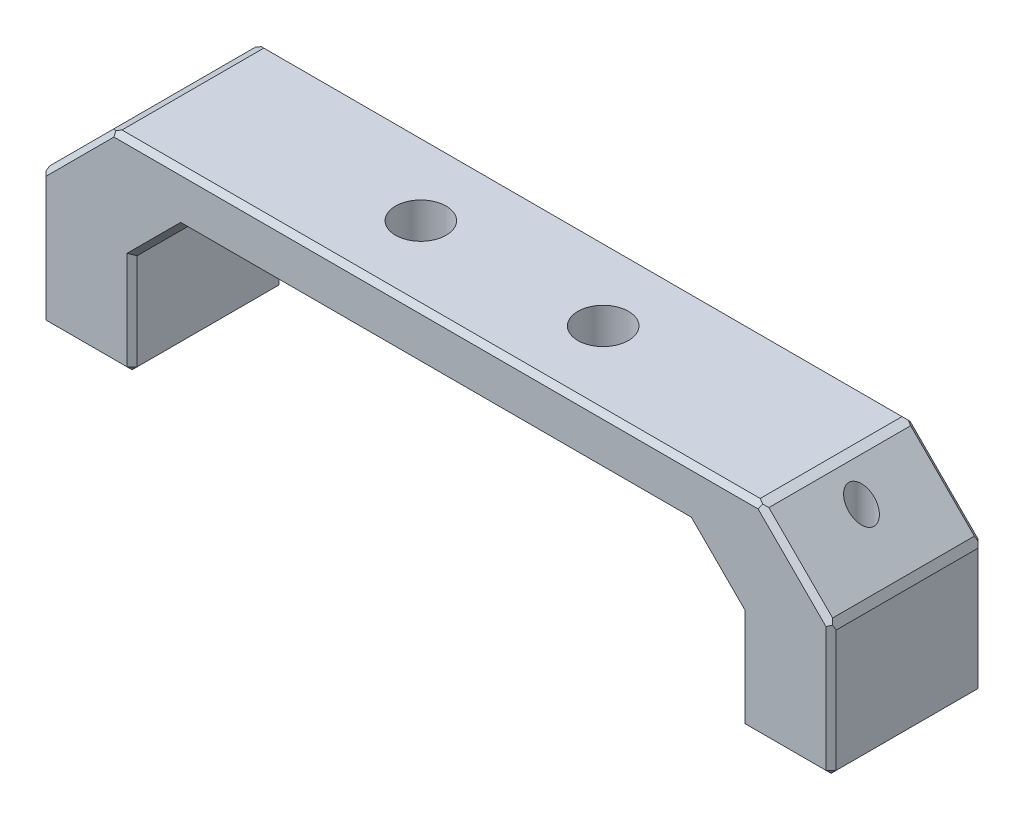
from build123d import *

# Parameters (mm, degrees)
BOSS_EXTRU_1_DEPTH      = 15
CHANFREIN1_SIZE         = 5
CHANFREIN2_SIZE         = 7
TROU_TARAUD_M6X1_01_D   = 5
TROU_TARAUD_M3X0_51_D   = 2.5
CHANFREIN6_SIZE         = 0.5
CHANFREIN10_SIZE        = 0.5
CHANFREIN10_EDGE_2_SIZE = 0.5
CHANFREIN10_EDGE_3_SIZE = 0.5
CHANFREIN10_EDGE_4_SIZE = 0.5


with BuildPart() as part:
    # Esquisse1 → Boss.-Extru.1 (new body)
    with BuildSketch(Plane.XY):
        Polygon((-30, 0), (-39, 0), (-39, 20), (39, 20), (39, 0), (30, 0), (30, 15), (-30, 15), align=None)
    extrude(amount=BOSS_EXTRU_1_DEPTH)

    # Chanfrein1
    chanfrein1_edges = [part.edges().sort_by_distance(p)[0] for p in [
        (30, 15, 7.5),
        (-30, 15, 7.5),
    ]]
    chamfer(chanfrein1_edges, length=CHANFREIN1_SIZE)

    # Chanfrein2
    chanfrein2_edges = [part.edges().sort_by_distance(p)[0] for p in [
        (-39, 20, 7.5),
        (39, 20, 7.5),
    ]]
    chamfer(chanfrein2_edges, length=CHANFREIN2_SIZE)

    # Trou taraudé M6x1.01 (through all)
    with Locations(Plane(origin=(0, 20, 0), x_dir=(1, 0, 0), z_dir=(0, 1, 0))):
        with Locations((9, -7.5), (-9, -7.5)):
            Hole(TROU_TARAUD_M6X1_01_D / 2)

    # Trou taraudé M3x0.51 (through all)
    with Locations(Plane(origin=(0, 0, 0), x_dir=(-1, 0, 0), z_dir=(0, -1, 0))):
        with Locations((-34.5, -7.5), (34.5, -7.5)):
            Hole(TROU_TARAUD_M3X0_51_D / 2)

    # Chanfrein6
    chanfrein6_edges = [part.edges().sort_by_distance(p)[0] for p in [
        (34.5, 0, 0),
        (-30, 5, 0),
        (-30, 0, 7.5),
        (-39, 0, 7.5),
        (39, 0, 7.5),
        (30, 0, 7.5),
        (34.5, 0, 15),
        (39, 6.5, 15),
        (0, 15, 0),
        (0, 15, 15),
        (30, 5, 0),
        (30, 5, 15),
        (-27.5, 12.5, 0),
        (-27.5, 12.5, 15),
        (27.5, 12.5, 0),
        (27.5, 12.5, 15),
        (-34.5, 0, 15),
        (0, 20, 0),
        (0, 20, 15),
        (-39, 6.5, 0),
        (-35.5, 16.5, 0),
        (35.5, 16.5, 0),
        (-39, 6.5, 15),
        (-35.5, 16.5, 15),
        (35.5, 16.5, 15),
        (-30, 5, 15),
        (-34.5, 0, 0),
        (39, 6.5, 0),
    ]]
    chamfer(chanfrein6_edges, length=CHANFREIN6_SIZE)

    # Chanfrein10
    chanfrein10_edges = [part.edges().sort_by_distance(p)[0] for p in [
        (39, 13, 7.5),
    ]]
    chamfer(chanfrein10_edges, length=CHANFREIN10_SIZE)

    # Chanfrein10 edge 2
    chanfrein10_edge_2_edges = [part.edges().sort_by_distance(p)[0] for p in [
        (32, 20, 7.5),
    ]]
    chamfer(chanfrein10_edge_2_edges, length=CHANFREIN10_EDGE_2_SIZE)

    # Chanfrein10 edge 3
    chanfrein10_edge_3_edges = [part.edges().sort_by_distance(p)[0] for p in [
        (-32, 20, 7.5),
    ]]
    chamfer(chanfrein10_edge_3_edges, length=CHANFREIN10_EDGE_3_SIZE)

    # Chanfrein10 edge 4
    chanfrein10_edge_4_edges = [part.edges().sort_by_distance(p)[0] for p in [
        (-39, 13, 7.5),
    ]]
    chamfer(chanfrein10_edge_4_edges, length=CHANFREIN10_EDGE_4_SIZE)


solid = part.part
